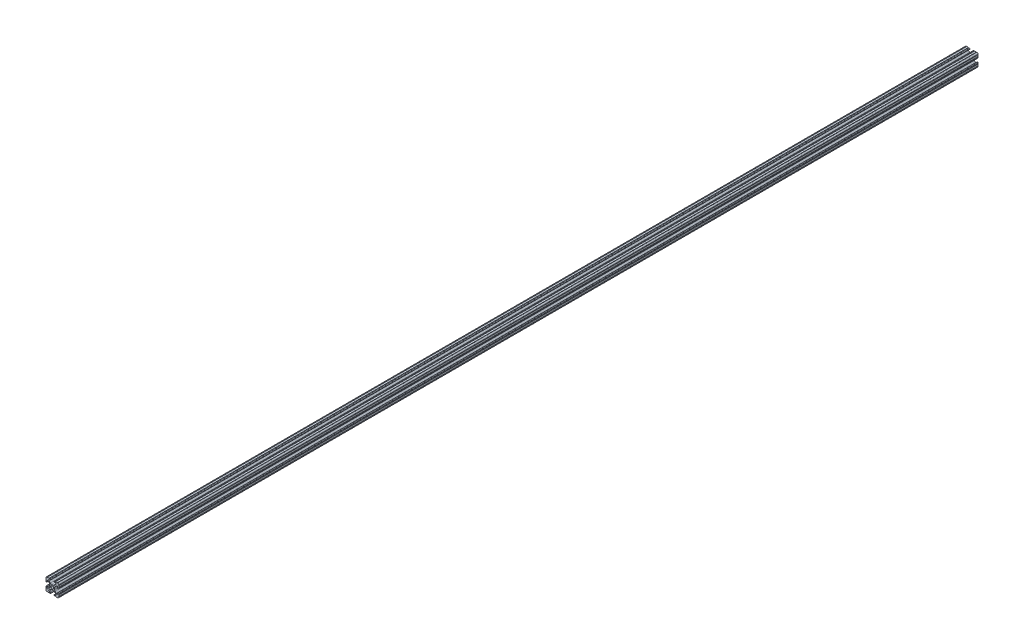
from build123d import *

# Parameters (mm, degrees)
SKETCH1_R               = 2.6035
BOSS_EXTRUDE1_DEPTH     = 914.4
SKETCH2_R               = 3.175
CUT_EXTRUDE1_DEPTH      = 915.65008745
CUT_EXTRUDE1_DEPTH_BACK = 915.65008745
SKETCH3_R               = 3.175
CUT_EXTRUDE2_DEPTH      = 915.649848696
CUT_EXTRUDE2_DEPTH_BACK = 915.649848696


with BuildPart() as part:
    # Sketch1 → Boss-Extrude1 (new, symmetric)
    with BuildSketch(Plane.XY):
        with BuildLine():
            Line((-7.179650497, -8.645192506), (-3.952270251, -5.423690499))
            ThreePointArc((-3.952270251, -5.423690499), (-2.922936451, -4.736929036), (-1.709253557, -4.4958))
            Line((-1.709253557, -4.4958), (1.709253557, -4.4958))
            ThreePointArc((1.709253557, -4.4958), (2.922936451, -4.736929036), (3.952270251, -5.423690499))
            Line((3.952270251, -5.423690499), (7.179650497, -8.645192506))
            ThreePointArc((7.179650497, -8.645192506), (7.41473083, -9.822813117), (6.416408329, -10.4902))
            Line((6.416408329, -10.4902), (4.287512407, -10.4902))
            ThreePointArc((4.287512407, -10.4902), (3.54574862, -10.79744862), (3.2385, -11.539212407))
            Line((3.2385, -11.539212407), (3.2385, -11.650987593))
            ThreePointArc((3.2385, -11.650987593), (3.54574862, -12.39275138), (4.287512407, -12.7))
            Line((4.287512407, -12.7), (5.317126718, -12.7))
            ThreePointArc((5.317126718, -12.7), (5.825126718, -12.192), (6.333126718, -12.7))
            Line((6.333126718, -12.7), (9.550443118, -12.7))
            ThreePointArc((9.550443118, -12.7), (10.058366869, -12.192000006), (10.566443095, -12.699847501))
            ThreePointArc((10.566443095, -12.699847501), (12.082537762, -12.08250727), (12.699846982, -10.566399977))
            ThreePointArc((12.699846982, -10.566399977), (12.192000006, -10.058323491), (12.7, -9.5504))
            Line((12.7, -9.5504), (12.7, -6.3330836))
            ThreePointArc((12.7, -6.3330836), (12.192, -5.8250836), (12.7, -5.3170836))
            Line((12.7, -5.3170836), (12.7, -4.287469289))
            ThreePointArc((12.7, -4.287469289), (12.39275138, -3.545705502), (11.650987593, -3.238456882))
            Line((11.650987593, -3.238456882), (11.539212407, -3.238456882))
            ThreePointArc((11.539212407, -3.238456882), (10.79744862, -3.545705502), (10.4902, -4.287469289))
            Line((10.4902, -4.287469289), (10.4902, -6.402089023))
            ThreePointArc((10.4902, -6.402089023), (9.856505071, -7.351067942), (8.737131347, -7.129408934))
            Line((8.737131347, -7.129408934), (5.441005833, -3.840816462))
            ThreePointArc((5.441005833, -3.840816462), (4.750877967, -2.809883091), (4.5085, -1.593185507))
            Line((4.5085, -1.593185507), (4.5085, 1.593185507))
            ThreePointArc((4.5085, 1.593185507), (4.750877967, 2.809883091), (5.441005833, 3.840816462))
            Line((5.441005833, 3.840816462), (8.737131347, 7.129408934))
            ThreePointArc((8.737131347, 7.129408934), (9.856505071, 7.351067942), (10.4902, 6.402089023))
            Line((10.4902, 6.402089023), (10.4902, 4.287469289))
            ThreePointArc((10.4902, 4.287469289), (10.79744862, 3.545705502), (11.539212407, 3.238456882))
            Line((11.539212407, 3.238456882), (11.650987593, 3.238456882))
            ThreePointArc((11.650987593, 3.238456882), (12.39275138, 3.545705502), (12.7, 4.287469289))
            Line((12.7, 4.287469289), (12.7, 5.3170836))
            ThreePointArc((12.7, 5.3170836), (12.192, 5.8250836), (12.7, 6.3330836))
            Line((12.7, 6.3330836), (12.7, 9.5504))
            ThreePointArc((12.7, 9.5504), (12.192000006, 10.058323491), (12.699846982, 10.566399977))
            ThreePointArc((12.699846982, 10.566399977), (12.082537762, 12.08250727), (10.566443095, 12.699847501))
            ThreePointArc((10.566443095, 12.699847501), (10.058366869, 12.192000006), (9.550443118, 12.7))
            Line((9.550443118, 12.7), (6.333126718, 12.7))
            ThreePointArc((6.333126718, 12.7), (5.825126718, 12.192), (5.317126718, 12.7))
            Line((5.317126718, 12.7), (4.287512407, 12.7))
            ThreePointArc((4.287512407, 12.7), (3.54574862, 12.39275138), (3.2385, 11.650987593))
            Line((3.2385, 11.650987593), (3.2385, 11.539212407))
            ThreePointArc((3.2385, 11.539212407), (3.54574862, 10.79744862), (4.287512407, 10.4902))
            Line((4.287512407, 10.4902), (6.476788598, 10.4902))
            ThreePointArc((6.476788598, 10.4902), (7.432222385, 9.85140422), (7.207036008, 8.724370562))
            Line((7.207036008, 8.724370562), (3.898272566, 5.423169045))
            ThreePointArc((3.898272566, 5.423169045), (2.869120213, 4.736787962), (1.655778399, 4.4958))
            Line((1.655778399, 4.4958), (-1.655778399, 4.4958))
            ThreePointArc((-1.655778399, 4.4958), (-2.869120213, 4.736787962), (-3.898272566, 5.423169045))
            Line((-3.898272566, 5.423169045), (-7.207036008, 8.724370562))
            ThreePointArc((-7.207036008, 8.724370562), (-7.432222385, 9.85140422), (-6.476788598, 10.4902))
            Line((-6.476788598, 10.4902), (-4.287512407, 10.4902))
            ThreePointArc((-4.287512407, 10.4902), (-3.54574862, 10.79744862), (-3.2385, 11.539212407))
            Line((-3.2385, 11.539212407), (-3.2385, 11.650987593))
            ThreePointArc((-3.2385, 11.650987593), (-3.54574862, 12.39275138), (-4.287512407, 12.7))
            Line((-4.287512407, 12.7), (-5.317126718, 12.7))
            ThreePointArc((-5.317126718, 12.7), (-5.825126718, 12.192), (-6.333126718, 12.7))
            Line((-6.333126718, 12.7), (-9.550443118, 12.7))
            ThreePointArc((-9.550443118, 12.7), (-10.058366869, 12.192000006), (-10.566443095, 12.699847501))
            ThreePointArc((-10.566443095, 12.699847501), (-12.082537762, 12.08250727), (-12.699846982, 10.566399977))
            ThreePointArc((-12.699846982, 10.566399977), (-12.192000006, 10.058323491), (-12.7, 9.5504))
            Line((-12.7, 9.5504), (-12.7, 6.3330836))
            ThreePointArc((-12.7, 6.3330836), (-12.192, 5.8250836), (-12.7, 5.3170836))
            Line((-12.7, 5.3170836), (-12.7, 4.287469289))
            ThreePointArc((-12.7, 4.287469289), (-12.39275138, 3.545705502), (-11.650987593, 3.238456882))
            Line((-11.650987593, 3.238456882), (-11.539212407, 3.238456882))
            ThreePointArc((-11.539212407, 3.238456882), (-10.79744862, 3.545705502), (-10.4902, 4.287469289))
            Line((-10.4902, 4.287469289), (-10.4902, 6.402089023))
            ThreePointArc((-10.4902, 6.402089023), (-9.856505071, 7.351067942), (-8.737131347, 7.129408934))
            Line((-8.737131347, 7.129408934), (-5.441005833, 3.840816462))
            ThreePointArc((-5.441005833, 3.840816462), (-4.750877967, 2.809883091), (-4.5085, 1.593185507))
            Line((-4.5085, 1.593185507), (-4.5085, -1.593185507))
            ThreePointArc((-4.5085, -1.593185507), (-4.750877967, -2.809883091), (-5.441005833, -3.840816462))
            Line((-5.441005833, -3.840816462), (-8.737131347, -7.129408934))
            ThreePointArc((-8.737131347, -7.129408934), (-9.856505071, -7.351067942), (-10.4902, -6.402089023))
            Line((-10.4902, -6.402089023), (-10.4902, -4.287469289))
            ThreePointArc((-10.4902, -4.287469289), (-10.79744862, -3.545705502), (-11.539212407, -3.238456882))
            Line((-11.539212407, -3.238456882), (-11.650987593, -3.238456882))
            ThreePointArc((-11.650987593, -3.238456882), (-12.39275138, -3.545705502), (-12.7, -4.287469289))
            Line((-12.7, -4.287469289), (-12.7, -5.3170836))
            ThreePointArc((-12.7, -5.3170836), (-12.192, -5.8250836), (-12.7, -6.3330836))
            Line((-12.7, -6.3330836), (-12.7, -9.5504))
            ThreePointArc((-12.7, -9.5504), (-12.192000006, -10.058323491), (-12.699846982, -10.566399977))
            ThreePointArc((-12.699846982, -10.566399977), (-12.082537762, -12.08250727), (-10.566443095, -12.699847501))
            ThreePointArc((-10.566443095, -12.699847501), (-10.058366869, -12.192000006), (-9.550443118, -12.7))
            Line((-9.550443118, -12.7), (-6.333126718, -12.7))
            ThreePointArc((-6.333126718, -12.7), (-5.825126718, -12.192), (-5.317126718, -12.7))
            Line((-5.317126718, -12.7), (-4.287512407, -12.7))
            ThreePointArc((-4.287512407, -12.7), (-3.54574862, -12.39275138), (-3.2385, -11.650987593))
            Line((-3.2385, -11.650987593), (-3.2385, -11.539212407))
            ThreePointArc((-3.2385, -11.539212407), (-3.54574862, -10.79744862), (-4.287512407, -10.4902))
            Line((-4.287512407, -10.4902), (-6.416408329, -10.4902))
            ThreePointArc((-6.416408329, -10.4902), (-7.41473083, -9.822813117), (-7.179650497, -8.645192506))
        make_face()
        Circle(SKETCH1_R, mode=Mode.SUBTRACT)
    extrude(amount=BOSS_EXTRUDE1_DEPTH, both=True)

    # Sketch2 → Cut-Extrude1 (cut, two sides)
    with BuildSketch(Plane(origin=(4.5085, 0, 0), x_dir=(0, 0, -1), z_dir=(1, 0, 0))) as cut_extrude1_sk:
        with Locations(Location((0, 0, 0), (0, 0, 149.881456627))):
            Circle(SKETCH2_R)
        with Locations(Location((76.2, 0, 0), (0, 0, 149.881456627))):
            Circle(SKETCH2_R)
        with Locations(Location((-76.2, 0, 0), (0, 0, 149.881456627))):
            Circle(SKETCH2_R)
    extrude(amount=CUT_EXTRUDE1_DEPTH, mode=Mode.SUBTRACT)
    extrude(cut_extrude1_sk.sketch, amount=-CUT_EXTRUDE1_DEPTH_BACK, mode=Mode.SUBTRACT)

    # Sketch3 → Cut-Extrude2 (cut, two sides)
    with BuildSketch(Plane(origin=(0, 4.4958, 0), x_dir=(1, 0, 0), z_dir=(0, 1, 0))) as cut_extrude2_sk:
        with Locations(Location((0, -901.7, 0), (0, 0, 237.428778052))):
            Circle(SKETCH3_R)
        with Locations(Location((0, 901.7, 0), (0, 0, 237.428778052))):
            Circle(SKETCH3_R)
    extrude(amount=CUT_EXTRUDE2_DEPTH, mode=Mode.SUBTRACT)
    extrude(cut_extrude2_sk.sketch, amount=-CUT_EXTRUDE2_DEPTH_BACK, mode=Mode.SUBTRACT)


solid = part.part
